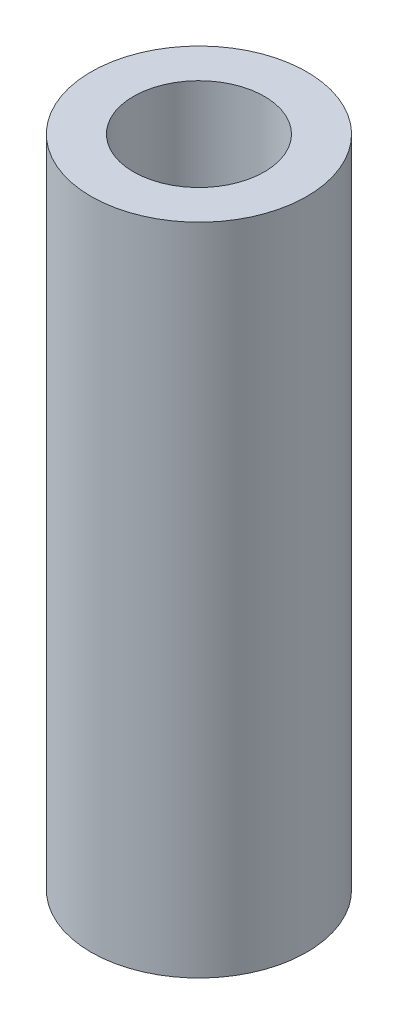
from build123d import *

# Parameters (mm, degrees)
SKETCH2_R           = 50.2539
SKETCH2_R_2         = 30.48
BOSS_EXTRUDE1_DEPTH = 304.8


with BuildPart() as part:
    # Sketch2 → Boss-Extrude1 (new body)
    with BuildSketch(Plane(origin=(0, 0, 0), x_dir=(1, 0, 0), z_dir=(0, 1, 0))):
        Circle(SKETCH2_R)
        Circle(SKETCH2_R_2, mode=Mode.SUBTRACT)
    extrude(amount=BOSS_EXTRUDE1_DEPTH)


solid = part.part
